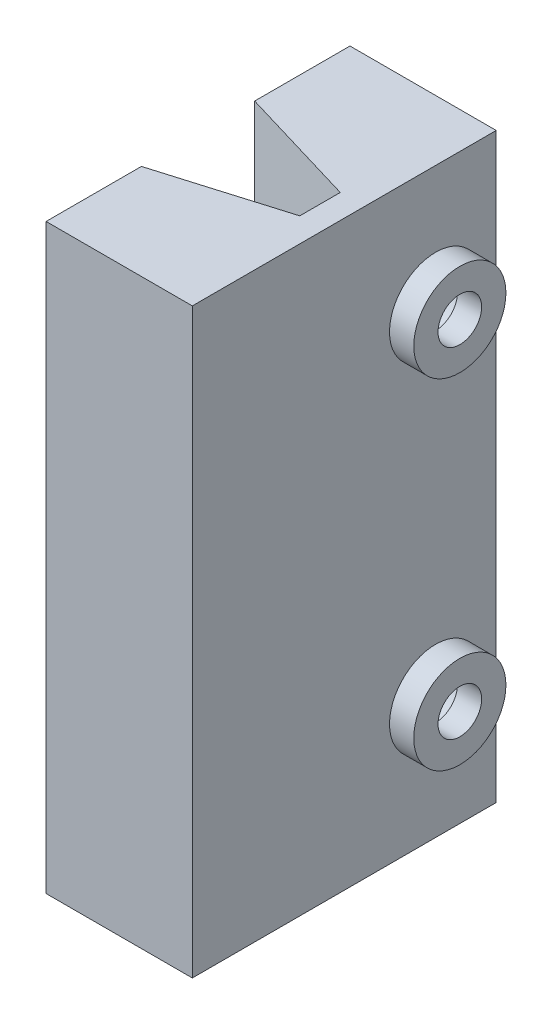
from build123d import *

# Parameters (mm, degrees)
BOSS_EXTRUDE1_DEPTH = 24
SKETCH3_R           = 1.9
SKETCH3_R_2         = 0.9
BOSS_EXTRUDE2_DEPTH = 1
SKETCH4_R           = 1.15
CUT_EXTRUDE2_DEPTH  = 4
CUT_EXTRUDE3_DEPTH  = 30


with BuildPart() as part:
    # Sketch1 → Boss-Extrude1 (new body)
    with BuildSketch(Plane(origin=(0, 0, 0), x_dir=(1, 0, 0), z_dir=(0, 1, 0))):
        Polygon((0.758759529, 5.315), (5, 5.315), (5, -7.215), (1.398203198, -7.215), (-1.03, -7.215), (-1.03, -1.785), (4, -1.785), (4, -0.115), (-1.03, -0.115), (-1.03, 5.315), align=None)
    extrude(amount=BOSS_EXTRUDE1_DEPTH)

    # Sketch3 → Boss-Extrude2 (add)
    with BuildSketch(Plane(origin=(5, 0, 0), x_dir=(0, 0, -1), z_dir=(1, 0, 0))):
        with Locations((2.815, 19)):
            Circle(SKETCH3_R)
        with Locations((2.815, 19)):
            Circle(SKETCH3_R_2, mode=Mode.SUBTRACT)
        with Locations((2.815, 5)):
            Circle(SKETCH3_R)
        with Locations((2.815, 5)):
            Circle(SKETCH3_R_2, mode=Mode.SUBTRACT)
    extrude(amount=BOSS_EXTRUDE2_DEPTH)

    # Sketch4 → Cut-Extrude2 (cut)
    with BuildSketch(Plane(origin=(5, 0, 0), x_dir=(0, 0, -1), z_dir=(1, 0, 0))):
        with Locations((2.815, 19)):
            Circle(SKETCH4_R)
        with Locations((2.815, 5)):
            Circle(SKETCH4_R)
    extrude(amount=-CUT_EXTRUDE2_DEPTH, mode=Mode.SUBTRACT)

    # Sketch6 → Cut-Extrude3 (cut)
    with BuildSketch(Plane(origin=(0, 24, 0), x_dir=(1, 0, 0), z_dir=(0, 1, 0))):
        Polygon((-1.03, -0.115), (4, -0.115), (-1.03, 1.385), align=None)
        Polygon((4, -1.785), (-1.03, -1.785), (-1.03, -3.285), align=None)
    extrude(amount=-CUT_EXTRUDE3_DEPTH, mode=Mode.SUBTRACT)


solid = part.part
